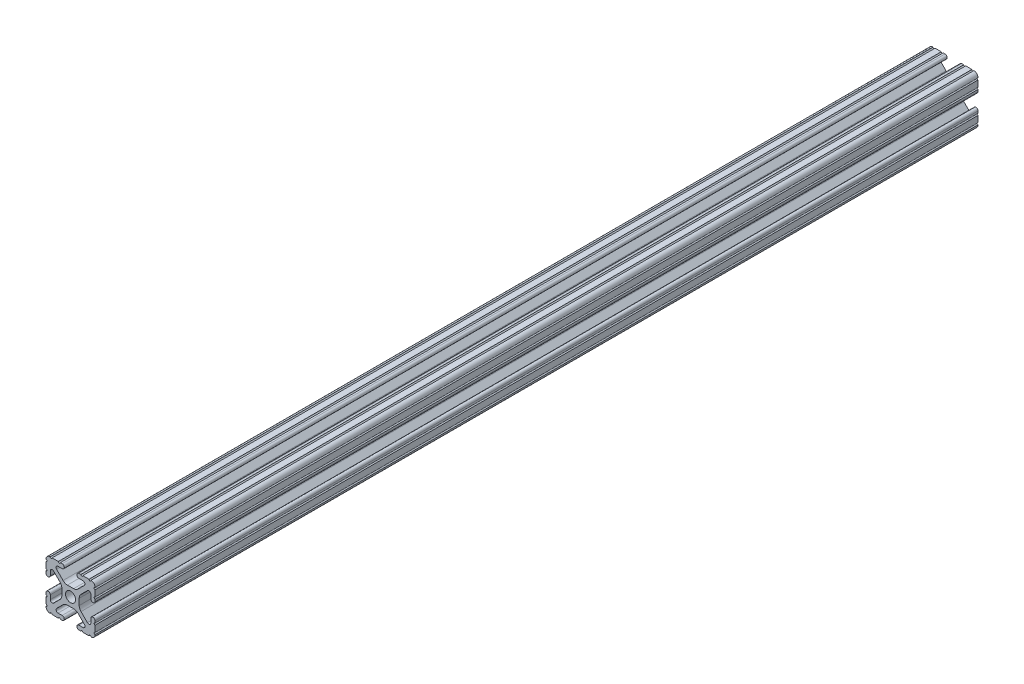
from build123d import *

# Parameters (mm, degrees)
SKETCH1_R           = 2.6035
BOSS_EXTRUDE1_DEPTH = 457.2


with BuildPart() as part:
    # Sketch1 → Boss-Extrude1 (new body)
    with BuildSketch(Plane(origin=(0, 0, -450.85), x_dir=(-1, 0, 0), z_dir=(0, 0, -1))):
        with BuildLine():
            Line((12.7, -9.5504), (12.7, -6.3330836))
            ThreePointArc((12.7, -6.3330836), (12.192, -5.8250836), (12.7, -5.3170836))
            Line((12.7, -5.3170836), (12.7, -4.3434))
            ThreePointArc((12.7, -4.3434), (11.5951, -3.2385), (10.4902, -4.3434))
            Line((10.4902, -4.3434), (10.4902, -6.474794456))
            ThreePointArc((10.4902, -6.474794456), (9.863006367, -7.413456061), (8.75577951, -7.193214945))
            Line((8.75577951, -7.193214945), (5.42573597, -3.863171405))
            ThreePointArc((5.42573597, -3.863171405), (4.737482484, -2.833127272), (4.4958, -1.618107374))
            Line((4.4958, -1.618107374), (4.4958, 1.618107374))
            ThreePointArc((4.4958, 1.618107374), (4.737482484, 2.833127272), (5.42573597, 3.863171405))
            Line((5.42573597, 3.863171405), (8.75577951, 7.193214945))
            ThreePointArc((8.75577951, 7.193214945), (9.863006367, 7.413456061), (10.4902, 6.474794456))
            Line((10.4902, 6.474794456), (10.4902, 4.343399971))
            ThreePointArc((10.4902, 4.343399971), (11.5951, 3.238499971), (12.7, 4.343399971))
            Line((12.7, 4.343399971), (12.7, 5.3170836))
            ThreePointArc((12.7, 5.3170836), (12.192, 5.8250836), (12.7, 6.3330836))
            Line((12.7, 6.3330836), (12.7, 9.5504))
            ThreePointArc((12.7, 9.5504), (12.192000006, 10.058323491), (12.699846982, 10.566399977))
            ThreePointArc((12.699846982, 10.566399977), (12.082522516, 12.082522516), (10.566399977, 12.699846982))
            ThreePointArc((10.566399977, 12.699846982), (10.058323491, 12.192000006), (9.5504, 12.7))
            Line((9.5504, 12.7), (6.3330836, 12.7))
            ThreePointArc((6.3330836, 12.7), (5.8250836, 12.192), (5.3170836, 12.7))
            Line((5.3170836, 12.7), (4.3434, 12.7))
            ThreePointArc((4.3434, 12.7), (3.2385, 11.5951), (4.3434, 10.4902))
            Line((4.3434, 10.4902), (6.474794456, 10.4902))
            ThreePointArc((6.474794456, 10.4902), (7.413456061, 9.863006367), (7.193214945, 8.75577951))
            Line((7.193214945, 8.75577951), (3.863171405, 5.42573597))
            ThreePointArc((3.863171405, 5.42573597), (2.833127272, 4.737482484), (1.618107374, 4.4958))
            Line((1.618107374, 4.4958), (-1.618107374, 4.4958))
            ThreePointArc((-1.618107374, 4.4958), (-2.833127272, 4.737482484), (-3.863171405, 5.42573597))
            Line((-3.863171405, 5.42573597), (-7.193214945, 8.75577951))
            ThreePointArc((-7.193214945, 8.75577951), (-7.413456061, 9.863006367), (-6.474794456, 10.4902))
            Line((-6.474794456, 10.4902), (-4.343399971, 10.4902))
            ThreePointArc((-4.343399971, 10.4902), (-3.238499971, 11.5951), (-4.343399971, 12.7))
            Line((-4.343399971, 12.7), (-5.3170836, 12.7))
            ThreePointArc((-5.3170836, 12.7), (-5.8250836, 12.192), (-6.3330836, 12.7))
            Line((-6.3330836, 12.7), (-9.5504, 12.7))
            ThreePointArc((-9.5504, 12.7), (-10.058323491, 12.192000006), (-10.566399977, 12.699846982))
            ThreePointArc((-10.566399977, 12.699846982), (-12.082522516, 12.082522516), (-12.699846982, 10.566399977))
            ThreePointArc((-12.699846982, 10.566399977), (-12.192000006, 10.058323491), (-12.7, 9.5504))
            Line((-12.7, 9.5504), (-12.7, 6.3330836))
            ThreePointArc((-12.7, 6.3330836), (-12.192, 5.8250836), (-12.7, 5.3170836))
            Line((-12.7, 5.3170836), (-12.7, 4.3434))
            ThreePointArc((-12.7, 4.3434), (-11.5951, 3.2385), (-10.4902, 4.3434))
            Line((-10.4902, 4.3434), (-10.4902, 6.474794456))
            ThreePointArc((-10.4902, 6.474794456), (-9.863006367, 7.413456061), (-8.75577951, 7.193214945))
            Line((-8.75577951, 7.193214945), (-5.42573597, 3.863171405))
            ThreePointArc((-5.42573597, 3.863171405), (-4.737482484, 2.833127272), (-4.4958, 1.618107374))
            Line((-4.4958, 1.618107374), (-4.4958, -1.618107374))
            ThreePointArc((-4.4958, -1.618107374), (-4.737482484, -2.833127272), (-5.42573597, -3.863171405))
            Line((-5.42573597, -3.863171405), (-8.75577951, -7.193214945))
            ThreePointArc((-8.75577951, -7.193214945), (-9.863006367, -7.413456061), (-10.4902, -6.474794456))
            Line((-10.4902, -6.474794456), (-10.4902, -4.343399971))
            ThreePointArc((-10.4902, -4.343399971), (-11.5951, -3.238499971), (-12.7, -4.343399971))
            Line((-12.7, -4.343399971), (-12.7, -5.3170836))
            ThreePointArc((-12.7, -5.3170836), (-12.192, -5.8250836), (-12.7, -6.3330836))
            Line((-12.7, -6.3330836), (-12.7, -9.5504))
            ThreePointArc((-12.7, -9.5504), (-12.192000006, -10.058323491), (-12.699846982, -10.566399977))
            ThreePointArc((-12.699846982, -10.566399977), (-12.082522516, -12.082522516), (-10.566399977, -12.699846982))
            ThreePointArc((-10.566399977, -12.699846982), (-10.058323491, -12.192000006), (-9.5504, -12.7))
            Line((-9.5504, -12.7), (-6.3330836, -12.7))
            ThreePointArc((-6.3330836, -12.7), (-5.8250836, -12.192), (-5.3170836, -12.7))
            Line((-5.3170836, -12.7), (-4.3434, -12.7))
            ThreePointArc((-4.3434, -12.7), (-3.2385, -11.5951), (-4.3434, -10.4902))
            Line((-4.3434, -10.4902), (-6.474794456, -10.4902))
            ThreePointArc((-6.474794456, -10.4902), (-7.413456061, -9.863006367), (-7.193214945, -8.75577951))
            Line((-7.193214945, -8.75577951), (-3.863171405, -5.42573597))
            ThreePointArc((-3.863171405, -5.42573597), (-2.833127272, -4.737482484), (-1.618107374, -4.4958))
            Line((-1.618107374, -4.4958), (1.618107374, -4.4958))
            ThreePointArc((1.618107374, -4.4958), (2.833127272, -4.737482484), (3.863171405, -5.42573597))
            Line((3.863171405, -5.42573597), (7.193214945, -8.75577951))
            ThreePointArc((7.193214945, -8.75577951), (7.413456061, -9.863006367), (6.474794456, -10.4902))
            Line((6.474794456, -10.4902), (4.343399971, -10.4902))
            ThreePointArc((4.343399971, -10.4902), (3.238499971, -11.5951), (4.343399971, -12.7))
            Line((4.343399971, -12.7), (5.3170836, -12.7))
            ThreePointArc((5.3170836, -12.7), (5.8250836, -12.192), (6.3330836, -12.7))
            Line((6.3330836, -12.7), (9.5504, -12.7))
            ThreePointArc((9.5504, -12.7), (10.058323491, -12.192000006), (10.566399977, -12.699846982))
            ThreePointArc((10.566399977, -12.699846982), (12.082522516, -12.082522516), (12.699846982, -10.566399977))
            ThreePointArc((12.699846982, -10.566399977), (12.192000006, -10.058323491), (12.7, -9.5504))
        make_face()
        Circle(SKETCH1_R, mode=Mode.SUBTRACT)
    extrude(amount=-BOSS_EXTRUDE1_DEPTH)


solid = part.part
